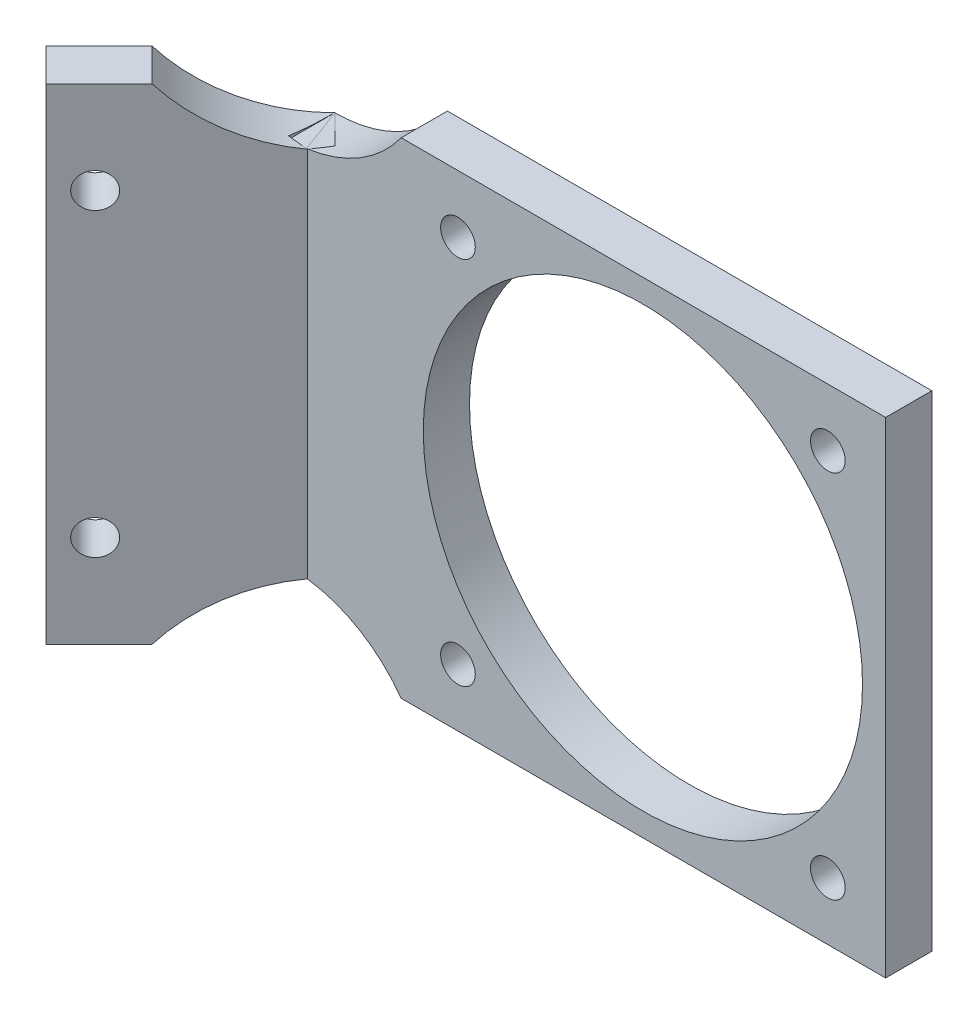
from build123d import *

# Parameters (mm, degrees)
BOSS_EXTRUDE1_DEPTH = 42
CUT_EXTRUDE1_REACH  = 14.828
SKETCH2_R           = 1.5
CUT_EXTRUDE2_REACH  = 6
SKETCH3_R           = 1.5
SKETCH3_R_2         = 19
CUT_EXTRUDE3_DEPTH  = 4
CUT_EXTRUDE4_DEPTH  = 4


with BuildPart() as part:
    # Sketch1 → Boss-Extrude1 (new body)
    with BuildSketch(Plane(origin=(0, 0, 0), x_dir=(1, 0, 0), z_dir=(0, 1, 0))):
        Polygon((0, 0), (51.656854249, 0), (51.656854249, -4), (1.656854249, -4), (-9.656854249, -15.313708499), (-12.485281374, -12.485281374), align=None)
    extrude(amount=BOSS_EXTRUDE1_DEPTH)

    # Sketch2 → Cut-Extrude1 (cut, up to next)
    with BuildSketch(Plane(origin=(2.828427125, 0, 2.828427125), x_dir=(0.707106781, 0, -0.707106781), z_dir=(0.707106781, 0, 0.707106781)), mode=Mode.PRIVATE) as cut_extrude1_sk1:
        with Locations((-14.656854249, 34)):
            Circle(SKETCH2_R)
    cut_extrude1_tool1 = extrude(cut_extrude1_sk1.sketch, amount=-CUT_EXTRUDE1_REACH, mode=Mode.PRIVATE) & part.part
    add(cut_extrude1_tool1.solids().sort_by_distance((-7.535534, 34, 13.192388))[0], mode=Mode.SUBTRACT)
    # Sketch2 → Cut-Extrude1 (cut, up to next)
    with BuildSketch(Plane(origin=(2.828427125, 0, 2.828427125), x_dir=(0.707106781, 0, -0.707106781), z_dir=(0.707106781, 0, 0.707106781)), mode=Mode.PRIVATE) as cut_extrude1_sk2:
        with Locations((-14.656854249, 8)):
            Circle(SKETCH2_R)
    cut_extrude1_tool2 = extrude(cut_extrude1_sk2.sketch, amount=-CUT_EXTRUDE1_REACH, mode=Mode.PRIVATE) & part.part
    add(cut_extrude1_tool2.solids().sort_by_distance((-7.535534, 8, 13.192388))[0], mode=Mode.SUBTRACT)

    # Sketch3 → Cut-Extrude2 (cut, up to next)
    with BuildSketch(Plane.XY.offset(4), mode=Mode.PRIVATE) as cut_extrude2_sk1:
        with Locations((14.656854249, 37)):
            Circle(SKETCH3_R)
    cut_extrude2_tool1 = extrude(cut_extrude2_sk1.sketch, amount=-CUT_EXTRUDE2_REACH, mode=Mode.PRIVATE) & part.part
    add(cut_extrude2_tool1.solids().sort_by_distance((14.656854, 37, 4))[0], mode=Mode.SUBTRACT)
    # Sketch3 → Cut-Extrude2 (cut, up to next)
    with BuildSketch(Plane.XY.offset(4), mode=Mode.PRIVATE) as cut_extrude2_sk2:
        with Locations((46.656854249, 37)):
            Circle(SKETCH3_R)
    cut_extrude2_tool2 = extrude(cut_extrude2_sk2.sketch, amount=-CUT_EXTRUDE2_REACH, mode=Mode.PRIVATE) & part.part
    add(cut_extrude2_tool2.solids().sort_by_distance((46.656854, 37, 4))[0], mode=Mode.SUBTRACT)
    # Sketch3 → Cut-Extrude2 (cut, up to next)
    with BuildSketch(Plane.XY.offset(4), mode=Mode.PRIVATE) as cut_extrude2_sk3:
        with Locations((46.656854249, 5)):
            Circle(SKETCH3_R)
    cut_extrude2_tool3 = extrude(cut_extrude2_sk3.sketch, amount=-CUT_EXTRUDE2_REACH, mode=Mode.PRIVATE) & part.part
    add(cut_extrude2_tool3.solids().sort_by_distance((46.656854, 5, 4))[0], mode=Mode.SUBTRACT)
    # Sketch3 → Cut-Extrude2 (cut, up to next)
    with BuildSketch(Plane.XY.offset(4), mode=Mode.PRIVATE) as cut_extrude2_sk4:
        with Locations((14.656854249, 5)):
            Circle(SKETCH3_R)
    cut_extrude2_tool4 = extrude(cut_extrude2_sk4.sketch, amount=-CUT_EXTRUDE2_REACH, mode=Mode.PRIVATE) & part.part
    add(cut_extrude2_tool4.solids().sort_by_distance((14.656854, 5, 4))[0], mode=Mode.SUBTRACT)
    # Sketch3 → Cut-Extrude2 (cut, up to next)
    with BuildSketch(Plane.XY.offset(4), mode=Mode.PRIVATE) as cut_extrude2_sk5:
        with Locations((30.656854249, 21)):
            Circle(SKETCH3_R_2)
    cut_extrude2_tool5 = extrude(cut_extrude2_sk5.sketch, amount=-CUT_EXTRUDE2_REACH, mode=Mode.PRIVATE) & part.part
    add(cut_extrude2_tool5.solids().sort_by_distance((30.656854, 21, 4))[0], mode=Mode.SUBTRACT)

    # Sketch6 → Cut-Extrude3 (cut)
    with BuildSketch(Plane(origin=(0, 0, 0), x_dir=(-0.707106781, 0, 0.707106781), z_dir=(-0.707106781, 0, -0.707106781))):
        with BuildLine():
            Line((0, 5), (0, 0))
            Line((0, 0), (11.180339887, 0))
            ThreePointArc((11.180339887, 0), (6.123724357, 3.693063938), (0, 5))
        make_face()
        with BuildLine():
            Line((0, 37), (0, 42))
            Line((0, 42), (11.180339887, 42))
            ThreePointArc((11.180339887, 42), (6.123724357, 38.306936062), (0, 37))
        make_face()
    extrude(amount=-CUT_EXTRUDE3_DEPTH, mode=Mode.SUBTRACT)

    # Sketch7 → Cut-Extrude4 (cut)
    with BuildSketch(Plane(origin=(0, 0, 0), x_dir=(-1, 0, 0), z_dir=(0, 0, -1))):
        with BuildLine():
            Line((-9.746794345, 42), (0, 42))
            Line((0, 42), (0, 37))
            ThreePointArc((0, 37), (-5.477225575, 38.322921748), (-9.746794345, 42))
        make_face()
        with BuildLine():
            Line((-9.746794345, 0), (0, 0))
            Line((0, 0), (0, 5))
            ThreePointArc((0, 5), (-5.477225575, 3.677078252), (-9.746794345, 0))
        make_face()
    extrude(amount=-CUT_EXTRUDE4_DEPTH, mode=Mode.SUBTRACT)


solid = part.part
